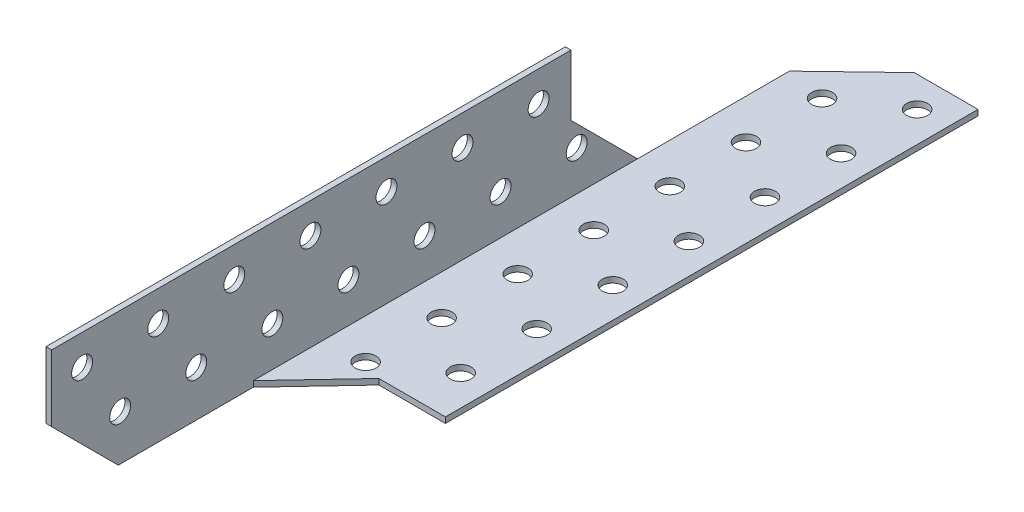
from build123d import *

# Parameters (mm, degrees)
SKETCH1_W               = 1.5
SKETCH1_H               = 33.5
SKETCH1_W_2             = 33.5
SKETCH1_H_2             = 1.5
BOSS_EXTRUDE1_DEPTH     = 210
CUT_EXTRUDE7_DEPTH      = 81
CUT_EXTRUDE7_DEPTH_BACK = 52
CUT_EXTRUDE8_DEPTH      = 52
CUT_EXTRUDE8_DEPTH_BACK = 52
SKETCH5_R               = 2.75
CUT_EXTRUDE9_DEPTH      = 52
SKETCH6_R               = 2.75
CUT_EXTRUDE10_DEPTH     = 52


with BuildPart() as part:
    # Sketch1 → Boss-Extrude1 (new body)
    with BuildSketch(Plane.XY):
        with Locations((0, 0.75)):
            Rectangle(SKETCH1_W, SKETCH1_H)
        with Locations((17.5, -16.75)):
            Rectangle(SKETCH1_W_2, SKETCH1_H_2)
        with Locations((0, -16.75)):
            Rectangle(SKETCH1_W, SKETCH1_H_2)
    extrude(amount=BOSS_EXTRUDE1_DEPTH)

    # Sketch2 → Cut-Extrude7 (cut, two sides)
    with BuildSketch(Plane(origin=(0, -16, 0), x_dir=(1, 0, 0), z_dir=(0, 1, 0))) as cut_extrude7_sk:
        Polygon((0.75, -16.061643836), (17.5, 0), (0.75, 0), align=None)
        Polygon((0.75, -56), (0.75, -16.061643836), (0.75, 0), (-0.75, 0), (-0.75, -17.5), (-0.75, -56), align=None)
        Polygon((34.25, -210), (34.25, -140), (16.75, -140), (0.75, -157), (0.75, -210), align=None)
    extrude(amount=CUT_EXTRUDE7_DEPTH, mode=Mode.SUBTRACT)
    extrude(cut_extrude7_sk.sketch, amount=-CUT_EXTRUDE7_DEPTH_BACK, mode=Mode.SUBTRACT)

    # Sketch4 → Cut-Extrude8 (cut, two sides)
    with BuildSketch(Plane(origin=(0.75, 0, 0), x_dir=(0, 0, -1), z_dir=(1, 0, 0))) as cut_extrude8_sk:
        Polygon((-73.5, 1.5), (-56, -16), (-56, 17.5), (-73.5, 17.5), align=None)
        Polygon((-210, 0), (-192.5, -17.5), (-210, -17.5), align=None)
    extrude(amount=CUT_EXTRUDE8_DEPTH, mode=Mode.SUBTRACT)
    extrude(cut_extrude8_sk.sketch, amount=-CUT_EXTRUDE8_DEPTH_BACK, mode=Mode.SUBTRACT)

    # Sketch5 → Cut-Extrude9 (cut)
    with BuildSketch(Plane(origin=(0.75, 0, 0), x_dir=(0, 0, -1), z_dir=(1, 0, 0))):
        with Locations((-72, -5.5)):
            Circle(SKETCH5_R)
        with Locations((-92, -5.5)):
            Circle(SKETCH5_R)
        with Locations((-112, -5.5)):
            Circle(SKETCH5_R)
        with Locations((-132, -5.5)):
            Circle(SKETCH5_R)
        with Locations((-152, -5.5)):
            Circle(SKETCH5_R)
        with Locations((-172, -5.5)):
            Circle(SKETCH5_R)
        with Locations((-192, -5.5)):
            Circle(SKETCH5_R)
        with Locations((-202, 9.5)):
            Circle(SKETCH5_R)
        with Locations((-182, 9.5)):
            Circle(SKETCH5_R)
        with Locations((-162, 9.5)):
            Circle(SKETCH5_R)
        with Locations((-142, 9.5)):
            Circle(SKETCH5_R)
        with Locations((-122, 9.5)):
            Circle(SKETCH5_R)
        with Locations((-102, 9.5)):
            Circle(SKETCH5_R)
        with Locations((-82, 9.5)):
            Circle(SKETCH5_R)
    extrude(amount=-CUT_EXTRUDE9_DEPTH, mode=Mode.SUBTRACT)

    # Sketch6 → Cut-Extrude10 (cut)
    with BuildSketch(Plane(origin=(0, -16, 0), x_dir=(1, 0, 0), z_dir=(0, 1, 0))):
        with Locations((26.25, -8)):
            Circle(SKETCH6_R)
        with Locations((26.25, -28)):
            Circle(SKETCH6_R)
        with Locations((26.25, -48)):
            Circle(SKETCH6_R)
        with Locations((26.25, -68)):
            Circle(SKETCH6_R)
        with Locations((26.25, -88)):
            Circle(SKETCH6_R)
        with Locations((26.25, -108)):
            Circle(SKETCH6_R)
        with Locations((26.25, -128)):
            Circle(SKETCH6_R)
        with Locations((11.25, -138)):
            Circle(SKETCH6_R)
        with Locations((11.25, -118)):
            Circle(SKETCH6_R)
        with Locations((11.25, -98)):
            Circle(SKETCH6_R)
        with Locations((11.25, -78)):
            Circle(SKETCH6_R)
        with Locations((11.25, -58)):
            Circle(SKETCH6_R)
        with Locations((11.25, -38)):
            Circle(SKETCH6_R)
        with Locations((11.25, -18)):
            Circle(SKETCH6_R)
    extrude(amount=-CUT_EXTRUDE10_DEPTH, mode=Mode.SUBTRACT)


solid = part.part
